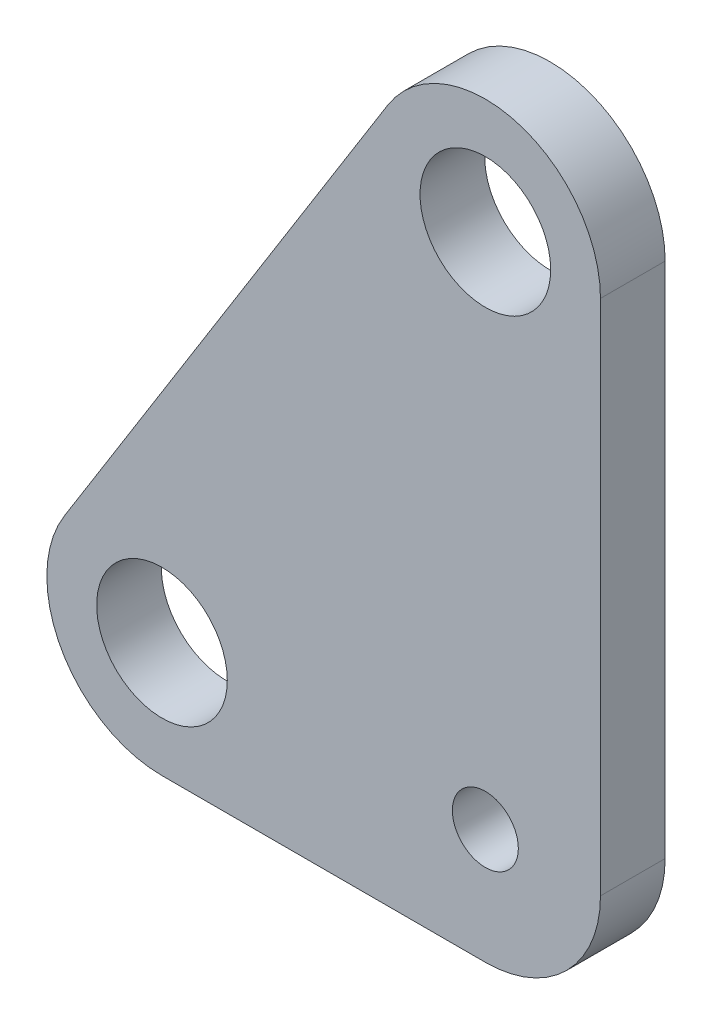
from build123d import *

# Parameters (mm, degrees)
ESQUISSE2_R        = 3.2385
ESQUISSE2_R_2      = 6.4135
BOSS_EXTRU_1_DEPTH = 6.35


with BuildPart() as part:
    # Esquisse2 → Boss.-Extru.1 (new body)
    with BuildSketch(Plane.XY):
        with BuildLine():
            Line((-41.33492483, 5.990578019), (-9.58492483, 56.790578019))
            ThreePointArc((-9.58492483, 56.790578019), (3.116039445, 61.664994578), (11.303, 50.8))
            Line((11.303, 50.8), (11.303, 0))
            ThreePointArc((11.303, 0), (7.992427948, -7.992427948), (0, -11.303))
            Line((0, -11.303), (-31.75, -11.303))
            ThreePointArc((-31.75, -11.303), (-41.636083966, -5.479338722), (-41.33492483, 5.990578019))
        make_face()
        Circle(ESQUISSE2_R, mode=Mode.SUBTRACT)
        with Locations((-31.75, 0)):
            Circle(ESQUISSE2_R_2, mode=Mode.SUBTRACT)
        with Locations((0, 50.8)):
            Circle(ESQUISSE2_R_2, mode=Mode.SUBTRACT)
    extrude(amount=BOSS_EXTRU_1_DEPTH)


solid = part.part
